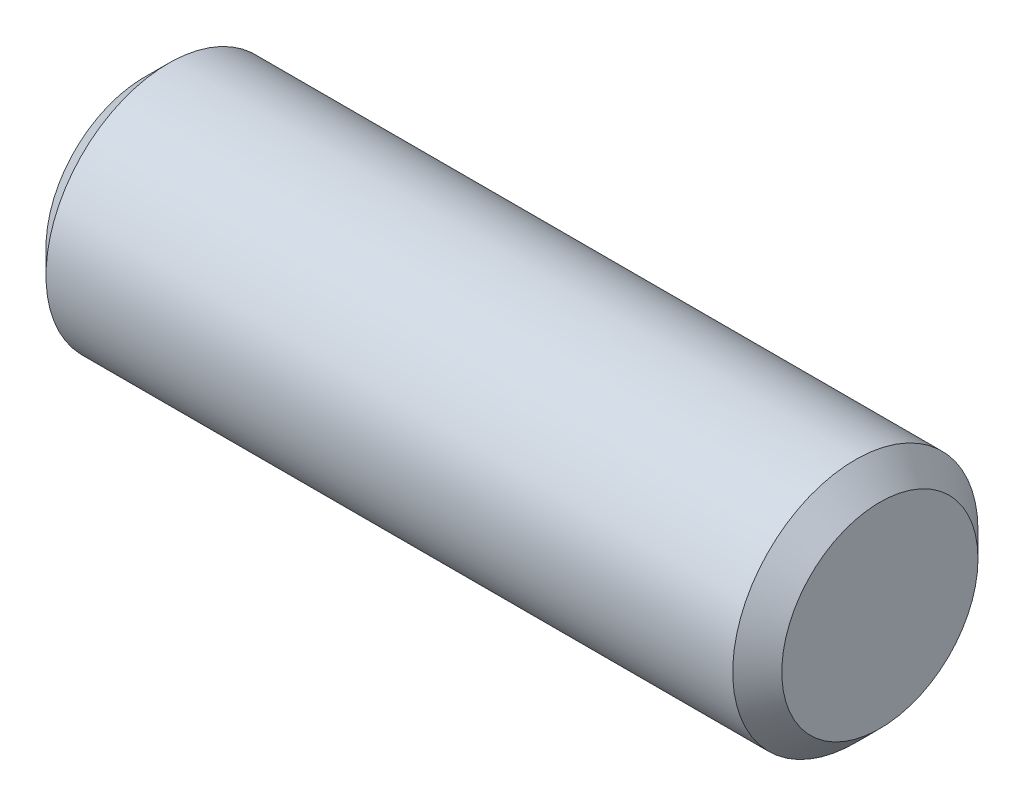
from build123d import *

# Parameters (mm, degrees)
SKETCH2_R           = 0.396875
EXTRUDE1_DEPTH      = 1.190625
EXTRUDE1_DEPTH_BACK = 1.190625
CHAMFER1_SIZE       = 0.079375


with BuildPart() as part:
    # Sketch2 → Extrude1 (new body, two sides)
    with BuildSketch(Plane(origin=(0, 0, 0), x_dir=(0, 0, -1), z_dir=(1, 0, 0))) as extrude1_sk:
        Circle(SKETCH2_R)
    extrude(amount=EXTRUDE1_DEPTH)
    extrude(extrude1_sk.sketch, amount=-EXTRUDE1_DEPTH_BACK)

    # Chamfer1
    chamfer1_edges = [part.edges().sort_by_distance(p)[0] for p in [
        (-1.190625, 0, 0.396875),
        (1.190625, 0, 0.396875),
    ]]
    chamfer(chamfer1_edges, length=CHAMFER1_SIZE)


solid = part.part
